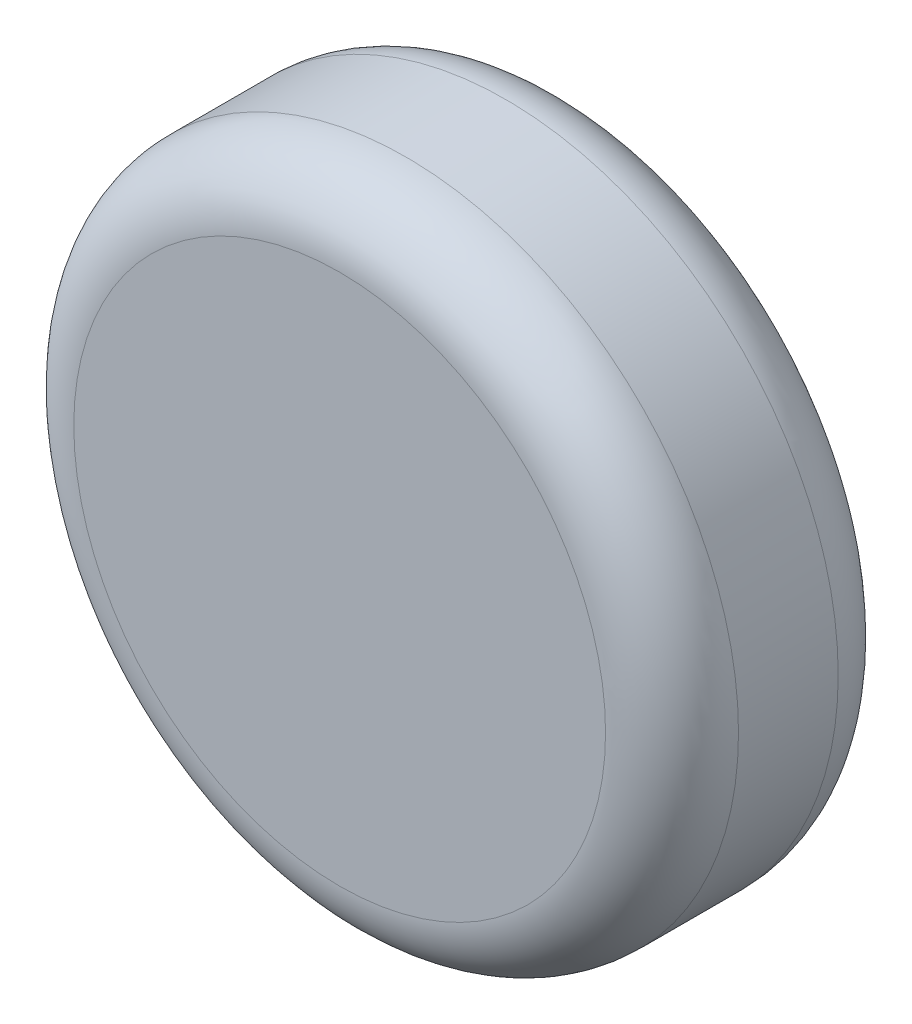
from build123d import *

# Parameters (mm, degrees)
SKETCH1_R           = 12.7
BOSS_EXTRUDE1_DEPTH = 8.89
SKETCH2_R           = 2.54
CUT_EXTRUDE1_DEPTH  = 6.35
FILLET1_R           = 2.54


with BuildPart() as part:
    # Sketch1 → Boss-Extrude1 (new body)
    with BuildSketch(Plane.XY):
        Circle(SKETCH1_R)
    extrude(amount=BOSS_EXTRUDE1_DEPTH)

    # Sketch2 → Cut-Extrude1 (cut)
    with BuildSketch(Plane(origin=(0, 0, 0), x_dir=(-1, 0, 0), z_dir=(0, 0, -1))):
        Circle(SKETCH2_R)
    extrude(amount=-CUT_EXTRUDE1_DEPTH, mode=Mode.SUBTRACT)

    # Fillet1
    fillet1_edges = [part.edges().sort_by_distance(p)[0] for p in [
        (-12.7, 0, 0),
        (-12.7, 0, 8.89),
    ]]
    fillet(fillet1_edges, radius=FILLET1_R)


solid = part.part
